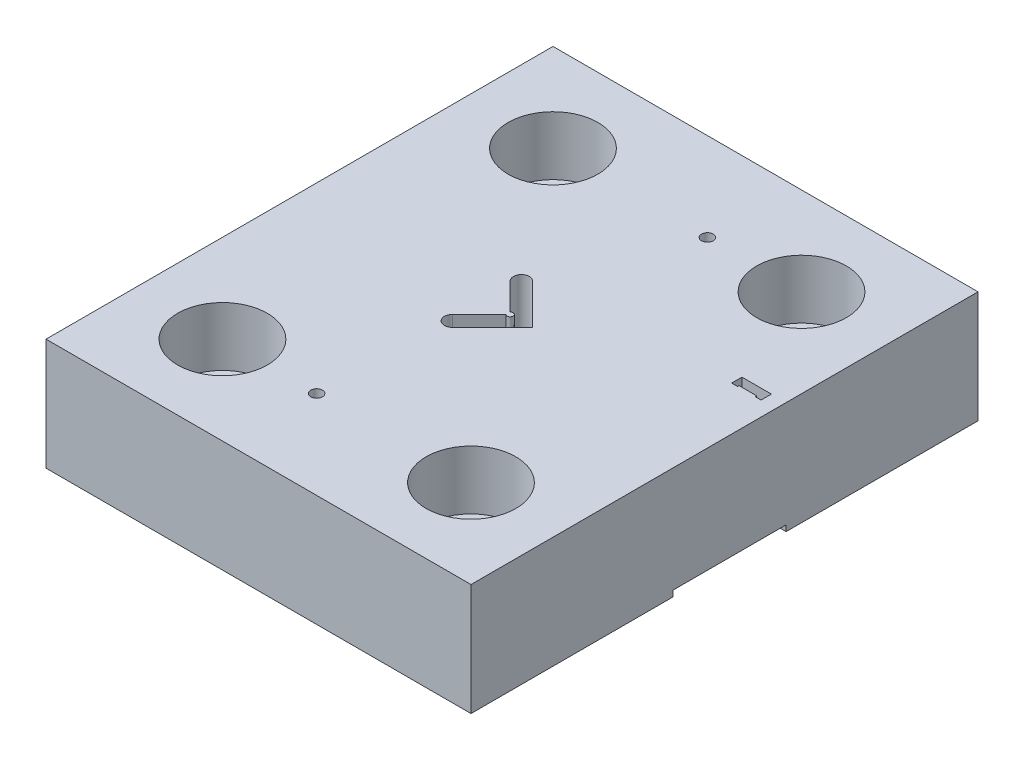
from build123d import *

# Parameters (mm, degrees)
SKETCH1_W           = 144.5
SKETCH1_H           = 172.38
BOSS_EXTRUDE1_DEPTH = 38
SKETCH2_R           = 10.5
SKETCH2_R_2         = 1.99
CUT_EXTRUDE1_DEPTH  = 39
CUT_EXTRUDE2_DEPTH  = 2
SKETCH4_R           = 15.25
CUT_EXTRUDE3_DEPTH  = 20


with BuildPart() as part:
    # Sketch1 → Boss-Extrude1 (new body)
    with BuildSketch(Plane(origin=(0, 0, 0), x_dir=(1, 0, 0), z_dir=(0, 1, 0))):
        Rectangle(SKETCH1_W, SKETCH1_H)
    extrude(amount=BOSS_EXTRUDE1_DEPTH)

    # Sketch2 → Cut-Extrude1 (cut, through all)
    with BuildSketch(Plane.XZ):
        with Locations((-42.25, -56.19)):
            Circle(SKETCH2_R)
        with Locations((10.25, -56.19)):
            Circle(SKETCH2_R_2)
        with Locations((42.25, -56.19)):
            Circle(SKETCH2_R)
        with Locations((-42.25, 56.19)):
            Circle(SKETCH2_R)
        with Locations((-10.25, 56.19)):
            Circle(SKETCH2_R_2)
        with Locations((42.25, 56.19)):
            Circle(SKETCH2_R)
        Polygon((57.25, -20.94), (67.25, -20.94), (67.25, -17.44), (65.25, -17.44), (65.25, -17.94), (59.25, -17.94), (59.25, -17.44), (57.25, -17.44), align=None)
        with BuildLine():
            Line((-1.333860018, -0.707106781), (-10.455537495, -9.828784258))
            ThreePointArc((-10.455537495, -9.828784258), (-10.455537495, -13.647160877), (-6.637160877, -13.647160877))
            Line((-6.637160877, -13.647160877), (7.01, 0))
            Line((7.01, 0), (-6.637160877, 13.647160877))
            ThreePointArc((-6.637160877, 13.647160877), (-10.455537495, 13.647160877), (-10.455537495, 9.828784258))
            Line((-10.455537495, 9.828784258), (-1.333860018, 0.707106781))
            ThreePointArc((-1.333860018, 0.707106781), (0.373246763, 0), (-1.333860018, -0.707106781))
        make_face()
    extrude(amount=-CUT_EXTRUDE1_DEPTH, mode=Mode.SUBTRACT)

    # Sketch3 → Cut-Extrude2 (cut)
    with BuildSketch(Plane.XZ):
        Polygon((72.25, 17.44), (-72.25, 17.44), (-72.25, -17.94), (57.25, -17.94), (57.25, -17.44), (59.25, -17.44), (59.25, -17.94), (65.25, -17.94), (65.25, -17.44), (67.25, -17.44), (67.25, -20.94), (72.25, -20.94), align=None)
        with BuildLine():
            Line((7.01, 0), (-6.637160877, -13.647160877))
            ThreePointArc((-6.637160877, -13.647160877), (-10.455537495, -13.647160877), (-10.455537495, -9.828784258))
            Line((-10.455537495, -9.828784258), (-1.333860018, -0.707106781))
            ThreePointArc((-1.333860018, -0.707106781), (0.373246763, 0), (-1.333860018, 0.707106781))
            Line((-1.333860018, 0.707106781), (-10.455537495, 9.828784258))
            ThreePointArc((-10.455537495, 9.828784258), (-10.455537495, 13.647160877), (-6.637160877, 13.647160877))
            Line((-6.637160877, 13.647160877), (7.01, 0))
        make_face(mode=Mode.SUBTRACT)
    extrude(amount=-CUT_EXTRUDE2_DEPTH, mode=Mode.SUBTRACT)

    # Sketch4 → Cut-Extrude3 (cut)
    with BuildSketch(Plane(origin=(0, 38, 0), x_dir=(1, 0, 0), z_dir=(0, 1, 0))):
        with Locations((-42.25, 56.19)):
            Circle(SKETCH4_R)
        with Locations((42.25, 56.19)):
            Circle(SKETCH4_R)
        with Locations((42.25, -56.19)):
            Circle(SKETCH4_R)
        with Locations((-42.25, -56.19)):
            Circle(SKETCH4_R)
    extrude(amount=-CUT_EXTRUDE3_DEPTH, mode=Mode.SUBTRACT)


solid = part.part
